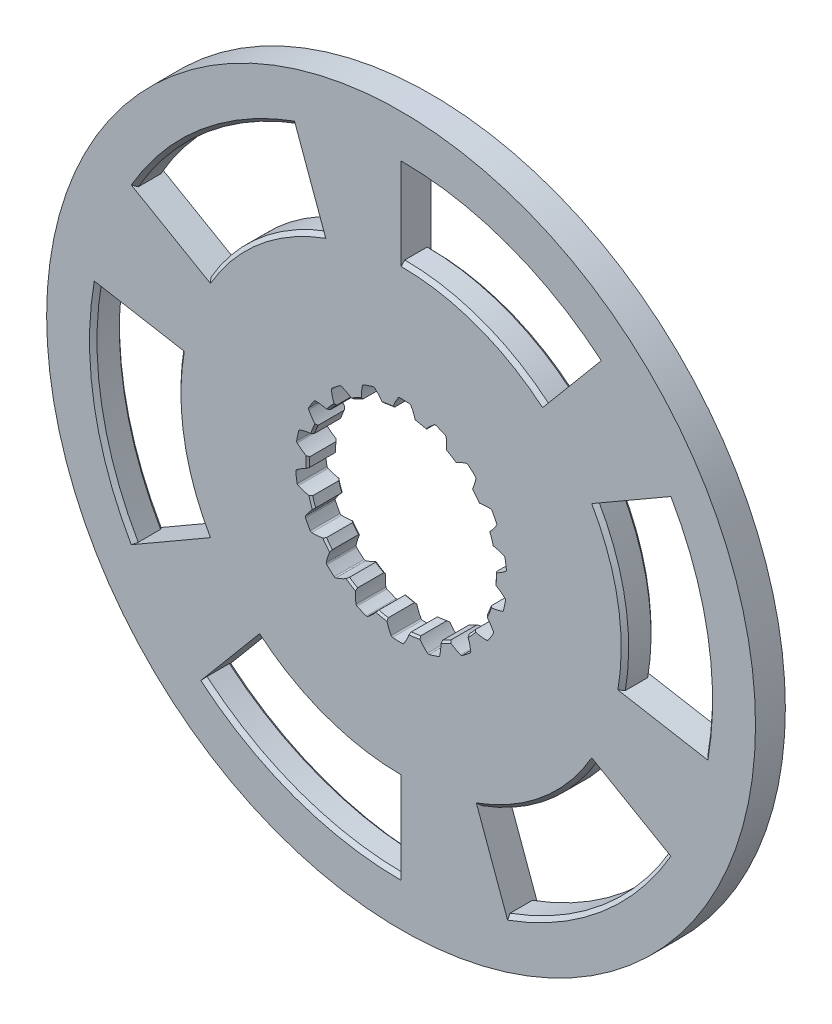
from build123d import *

# Parameters (mm, degrees)
SKETCH1_R                = 95
BOSS_EXTRUDE1_DEPTH      = 8
SKETCH2_R                = 25.05
CUT_EXTRUDE1_DEPTH       = 8
CUT_EXTRUDE3_DEPTH       = 8
FILLET1_R                = 0.48
CHAMFER1_SIZE            = 0.5
CIRPATTERN1_COUNT        = 18
FILLET1_OF_CIRPATTERN1_R = 0.48
CHAMFER2_SIZE            = 1


with BuildPart() as part:
    # Sketch1 → Boss-Extrude1 (new body)
    with BuildSketch(Plane.XY):
        Circle(SKETCH1_R)
        with BuildLine():
            Line((-20.5212086, 56.381557247), (-28.216661824, 77.524641215))
            ThreePointArc((-28.216661824, 77.524641215), (-53.029977799, 63.198666557), (-71.447095812, 41.25))
            Line((-71.447095812, 41.25), (-51.961524227, 30))
            ThreePointArc((-51.961524227, 30), (-38.567256581, 45.962666587), (-20.5212086, 56.381557247))
        make_face(mode=Mode.SUBTRACT)
        with BuildLine():
            Line((0, 60), (0, 82.5))
            ThreePointArc((0, 82.5), (28.216661824, 77.524641215), (53.029977799, 63.198666557))
            Line((53.029977799, 63.198666557), (38.567256581, 45.962666587))
            ThreePointArc((38.567256581, 45.962666587), (20.5212086, 56.381557247), (0, 60))
        make_face(mode=Mode.SUBTRACT)
        with BuildLine():
            Line((51.961524227, 30), (71.447095812, 41.25))
            ThreePointArc((71.447095812, 41.25), (81.246639624, 14.325974658), (81.246639624, -14.325974658))
            Line((81.246639624, -14.325974658), (59.088465181, -10.41889066))
            ThreePointArc((59.088465181, -10.41889066), (59.088465181, 10.41889066), (51.961524227, 30))
        make_face(mode=Mode.SUBTRACT)
        with BuildLine():
            Line((51.961524227, -30), (71.447095812, -41.25))
            ThreePointArc((71.447095812, -41.25), (53.029977799, -63.198666557), (28.216661824, -77.524641215))
            Line((28.216661824, -77.524641215), (20.5212086, -56.381557247))
            ThreePointArc((20.5212086, -56.381557247), (38.567256581, -45.962666587), (51.961524227, -30))
        make_face(mode=Mode.SUBTRACT)
        with BuildLine():
            Line((0, -60), (0, -82.5))
            ThreePointArc((0, -82.5), (-28.216661824, -77.524641215), (-53.029977799, -63.198666557))
            Line((-53.029977799, -63.198666557), (-38.567256581, -45.962666587))
            ThreePointArc((-38.567256581, -45.962666587), (-20.5212086, -56.381557247), (0, -60))
        make_face(mode=Mode.SUBTRACT)
        with BuildLine():
            Line((-51.961524227, -30), (-71.447095812, -41.25))
            ThreePointArc((-71.447095812, -41.25), (-81.246639624, -14.325974658), (-81.246639624, 14.325974658))
            Line((-81.246639624, 14.325974658), (-59.088465181, 10.41889066))
            ThreePointArc((-59.088465181, 10.41889066), (-59.088465181, -10.41889066), (-51.961524227, -30))
        make_face(mode=Mode.SUBTRACT)
    extrude(amount=BOSS_EXTRUDE1_DEPTH)

    # Sketch2 → Cut-Extrude1 (cut)
    with BuildSketch(Plane.XY.offset(8)):
        Circle(SKETCH2_R)
    extrude(amount=-CUT_EXTRUDE1_DEPTH, mode=Mode.SUBTRACT)

    # Sketch3 → Cut-Extrude3 (cut)
    with BuildSketch(Plane.XY.offset(8)):
        with BuildLine():
            ThreePointArc((25.046207093, 0.435901636), (24.801348621, 3.520739496), (24.178002116, 6.551848111))
            add(Edge.make_bspline(
                [(24.178002116, 6.551848111), (24.19988586, 6.549600911), (24.2926416, 6.539768978), (24.45603987, 6.520185272), (24.68938807, 6.486867567), (25.030584938, 6.42821746), (25.438806226, 6.344191754), (25.913898918, 6.226153096), (26.44974103, 6.068961917), (26.995315862, 5.882843134), (27.395894197, 5.729773968), (27.664244442, 5.618686092), (27.799250936, 5.560948424)],
                knots=[0.165762318, 0.165762318, 0.165762318, 0.165762318, 0.165762318, 0.174208854, 0.201574955, 0.228941013, 0.256307345, 0.307035032, 0.361767351, 0.41649966, 0.471231936, 0.527454206, 0.527454206, 0.527454206, 0.527454206, 0.527454206], degree=4))
            ThreePointArc((27.799250936, 5.560948424), (28.068592151, 3.98454949), (28.248614451, 2.395471058))
            add(Edge.make_bspline(
                [(25.046207093, 0.435901636), (25.066600849, 0.444150447), (25.152955725, 0.47940849), (25.304448219, 0.543693328), (25.519304815, 0.640637103), (25.830699041, 0.791927464), (26.199407503, 0.986244238), (26.622879397, 1.231840953), (27.093804227, 1.531950333), (27.566026512, 1.862553134), (27.908178717, 2.121058532), (28.135010542, 2.302441258), (28.248614451, 2.395471058)],
                knots=[0.165762318, 0.165762318, 0.165762318, 0.165762318, 0.165762318, 0.174208854, 0.201574955, 0.228941013, 0.256307345, 0.307035032, 0.361767351, 0.41649966, 0.471231936, 0.527454206, 0.527454206, 0.527454206, 0.527454206, 0.527454206], degree=4))
        make_face()
    cut_extrude3 = extrude(amount=-CUT_EXTRUDE3_DEPTH, mode=Mode.SUBTRACT)

    # Fillet1
    fillet1_edges = [part.edges().sort_by_distance(p)[0] for p in [
        (28.248614451, 2.395471058, 4),
        (27.799250936, 5.560948424, 4),
    ]]
    fillet(fillet1_edges, radius=FILLET1_R)

    # Chamfer1
    chamfer1_edges = [part.edges().sort_by_distance(p)[0] for p in [
        (-24.801348621, -3.520739496, 0),
        (-24.801348621, -3.520739496, 8),
    ]]
    chamfer(chamfer1_edges, length=CHAMFER1_SIZE)

    # CirPattern1: Cut-Extrude3 ×18 about axis
    cirpattern1_axis = Axis((0, 0, 0), (0, 0, 1))
    for i in range(1, CIRPATTERN1_COUNT):
        add(cut_extrude3.rotate(cirpattern1_axis, i * 360 / CIRPATTERN1_COUNT), mode=Mode.SUBTRACT)

    # Fillet1 of CirPattern1
    fillet1_of_cirpattern1_edges = [part.edges().sort_by_distance(p)[0] for p in [
        (25.725715193, 11.91260164, 4),
        (24.220794591, 14.733485988, 4),
        (20.099915011, 19.992896653, 4),
        (17.720952958, 22.128947699, 4),
        (12.049768435, 25.661753265, 4),
        (9.083702864, 26.855331729, 4),
        (2.546241951, 28.235423707, 4),
        (-0.649175857, 28.34256641, 4),
        (-7.264398891, 27.403485339, 4),
        (-10.303754388, 26.41126929, 4),
        (-16.198846016, 23.266282207, 4),
        (-18.715548073, 21.294383305, 4),
        (-23.179473242, 16.322822067, 4),
        (-24.869970448, 13.609080422, 4),
        (-27.364313902, 7.410588687, 4),
        (-28.024707345, 4.282321591, 4),
        (-28.248614451, -2.395471058, 4),
        (-27.799250936, -5.560948424, 4),
        (-25.725715193, -11.91260164, 4),
        (-24.220794591, -14.733485988, 4),
        (-20.099915011, -19.992896653, 4),
        (-17.720952958, -22.128947699, 4),
        (-12.049768435, -25.661753265, 4),
        (-9.083702864, -26.855331729, 4),
        (-2.546241951, -28.235423707, 4),
        (0.649175857, -28.34256641, 4),
        (7.264398891, -27.403485339, 4),
        (10.303754388, -26.41126929, 4),
        (16.198846016, -23.266282207, 4),
        (18.715548073, -21.294383305, 4),
        (23.179473242, -16.322822067, 4),
        (24.869970448, -13.609080422, 4),
        (27.364313902, -7.410588687, 4),
        (28.024707345, -4.282321591, 4),
    ]]
    fillet(fillet1_of_cirpattern1_edges, radius=FILLET1_OF_CIRPATTERN1_R)

    # Chamfer2
    chamfer2_edges = [part.edges().sort_by_distance(p)[0] for p in [
        (28.216661824, 77.524641215, 8),
        (-53.029977799, 63.198666557, 0),
        (-38.567256581, 45.962666587, 0),
        (-53.029977799, 63.198666557, 8),
        (-38.567256581, 45.962666587, 8),
        (-81.246639624, -14.325974658, 0),
        (-59.088465181, -10.41889066, 0),
        (-81.246639624, -14.325974658, 8),
        (-59.088465181, -10.41889066, 8),
        (-28.216661824, -77.524641215, 0),
        (-20.5212086, -56.381557247, 0),
        (-28.216661824, -77.524641215, 8),
        (-20.5212086, -56.381557247, 8),
        (81.246639624, 14.325974658, 0),
        (59.088465181, 10.41889066, 0),
        (81.246639624, 14.325974658, 8),
        (59.088465181, 10.41889066, 8),
        (53.029977799, -63.198666557, 0),
        (38.567256581, -45.962666587, 0),
        (53.029977799, -63.198666557, 8),
        (38.567256581, -45.962666587, 8),
        (20.5212086, 56.381557247, 0),
        (28.216661824, 77.524641215, 0),
        (20.5212086, 56.381557247, 8),
    ]]
    chamfer(chamfer2_edges, length=CHAMFER2_SIZE)


solid = part.part
